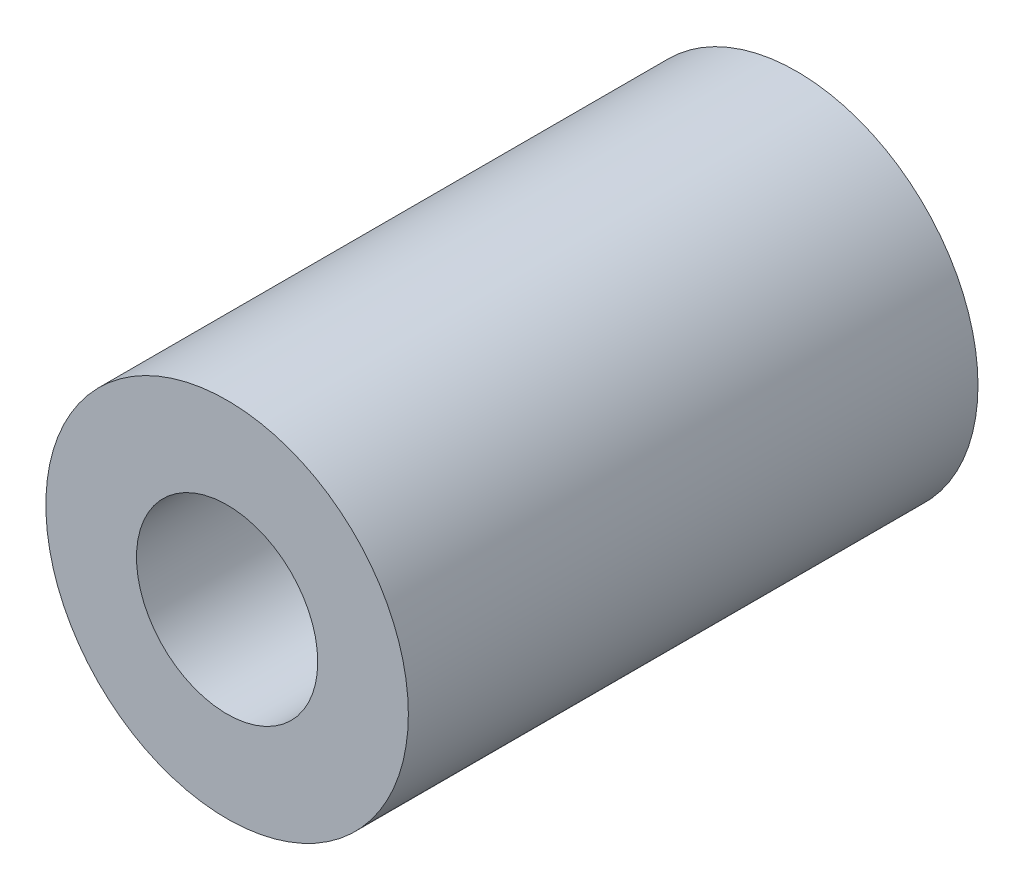
from build123d import *

# Parameters (mm, degrees)
SKETCH_1_R          = 7
EXTRUDE_1_DEPTH     = 22
SKETCH_2_R          = 3
CUT_EXTRUDE_1_DEPTH = 23
SKETCH_3_R          = 3.5
CUT_EXTRUDE_2_DEPTH = 7


with BuildPart() as part:
    # 草图1 → 凸台-拉伸1 (new body)
    with BuildSketch(Plane.XY):
        Circle(SKETCH_1_R)
    extrude(amount=EXTRUDE_1_DEPTH)

    # 草图2 → 切除-拉伸1 (cut, through all)
    with BuildSketch(Plane.XY.offset(22)):
        Circle(SKETCH_2_R)
    extrude(amount=-CUT_EXTRUDE_1_DEPTH, mode=Mode.SUBTRACT)

    # 草图3 → 切除-拉伸2 (cut)
    with BuildSketch(Plane.XY.offset(22)):
        Circle(SKETCH_3_R)
    extrude(amount=-CUT_EXTRUDE_2_DEPTH, mode=Mode.SUBTRACT)


solid = part.part
